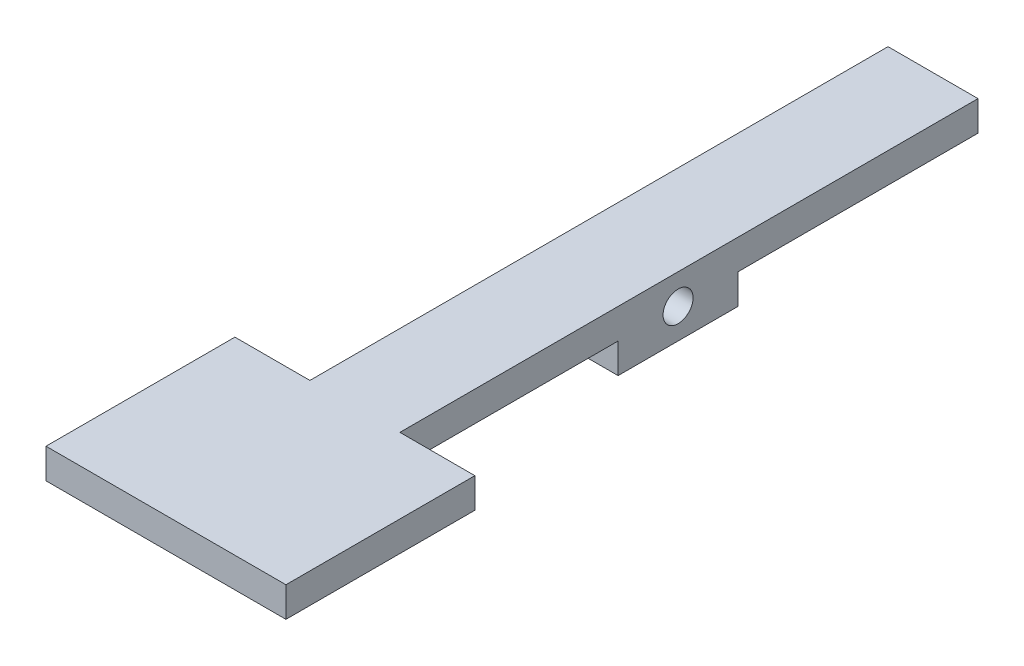
from build123d import *

# Parameters (mm, degrees)
SKETCH1_R           = 1.5875
BOSS_EXTRUDE1_DEPTH = 9.525
SKETCH3_W           = 15
SKETCH3_H           = 3.175
SKETCH3_W_2         = 5
BOSS_EXTRUDE2_DEPTH = 12.7


with BuildPart() as part:
    # Sketch1 → Boss-Extrude1 (new body)
    with BuildSketch(Plane(origin=(0, 0, 0), x_dir=(0, 0, -1), z_dir=(1, 0, 0))):
        Polygon((0, 1.5875), (0, -1.5875), (-25.4, -1.5875), (-25.4, -4.7625), (-38.1, -4.7625), (-38.1, -1.5875), (-76.2, -1.5875), (-76.2, 1.5875), align=None)
        with Locations((-31.75, -1.5875)):
            Circle(SKETCH1_R, mode=Mode.SUBTRACT)
    extrude(amount=BOSS_EXTRUDE1_DEPTH)

    # Sketch3 → Boss-Extrude2 (add, symmetric)
    with BuildSketch(Plane(origin=(4.7625, 0, 0), x_dir=(0, 0, -1), z_dir=(1, 0, 0))):
        with Locations((-68.7, 0)):
            Rectangle(SKETCH3_W, SKETCH3_H)
        with Locations((-78.7, 0)):
            Rectangle(SKETCH3_W_2, SKETCH3_H)
    extrude(amount=BOSS_EXTRUDE2_DEPTH, both=True)


solid = part.part
